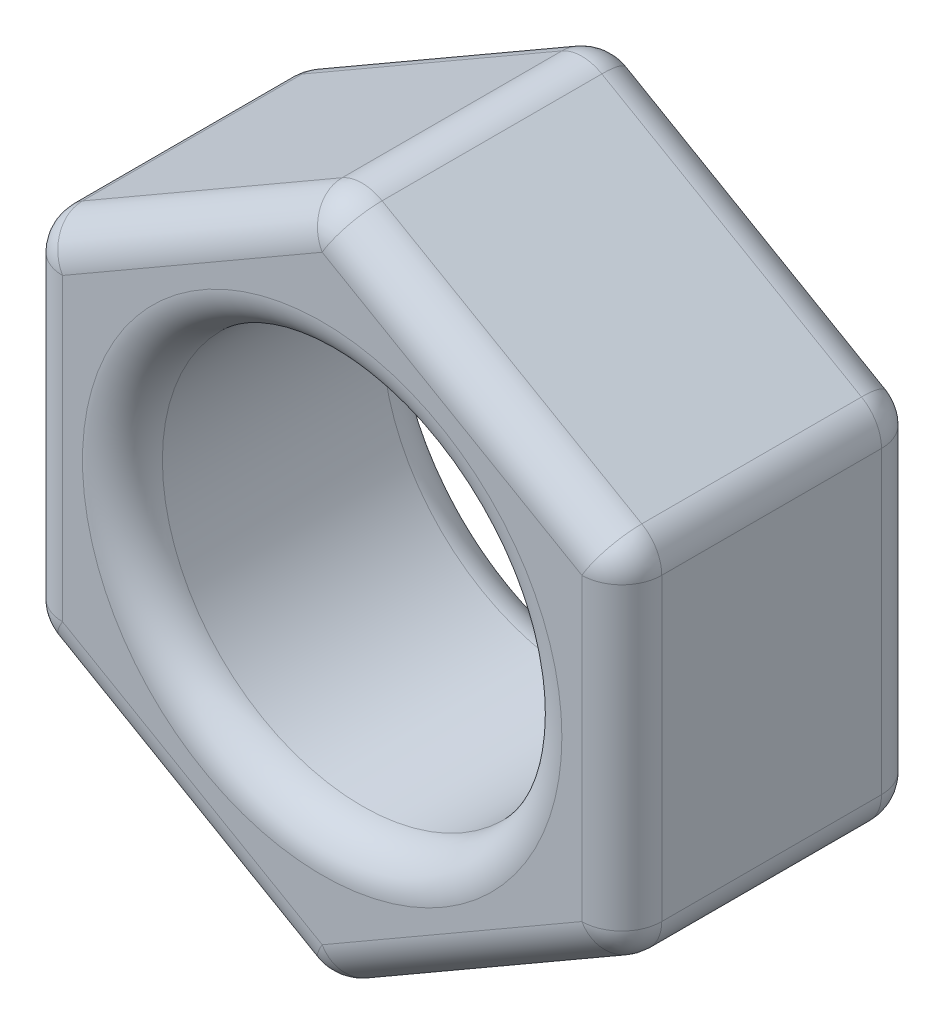
from build123d import *

# Parameters (mm, degrees)
SKETCH1_R      = 1
EXTRUDE1_DEPTH = 1.5
FILLET1_R      = 0.2


with BuildPart() as part:
    # Sketch1 → Extrude1 (new body)
    with BuildSketch(Plane.XY):
        Polygon((0, -1.732050808), (1.5, -0.866025404), (1.5, 0.866025404), (0, 1.732050808), (-1.5, 0.866025404), (-1.5, -0.866025404), align=None)
        Circle(SKETCH1_R, mode=Mode.SUBTRACT)
    extrude(amount=EXTRUDE1_DEPTH)

    # Fillet1
    fillet1_edges = [part.edges().sort_by_distance(p)[0] for p in [
        (1.5, 0, 1.5),
        (-1.5, -0.866025404, 0.75),
        (-1.5, 0.866025404, 0.75),
        (0, 1.732050808, 0.75),
        (1.5, 0.866025404, 0.75),
        (1.5, -0.866025404, 0.75),
        (0, -1.732050808, 0.75),
        (0.75, 1.299038106, 1.5),
        (-0.75, 1.299038106, 1.5),
        (-1, 0, 0),
        (-1, 0, 1.5),
        (-1.5, 0, 1.5),
        (-0.75, -1.299038106, 1.5),
        (-1.5, 0, 0),
        (-0.75, 1.299038106, 0),
        (0.75, 1.299038106, 0),
        (0.75, -1.299038106, 1.5),
        (1.5, 0, 0),
        (0.75, -1.299038106, 0),
        (-0.75, -1.299038106, 0),
    ]]
    fillet(fillet1_edges, radius=FILLET1_R)


solid = part.part
